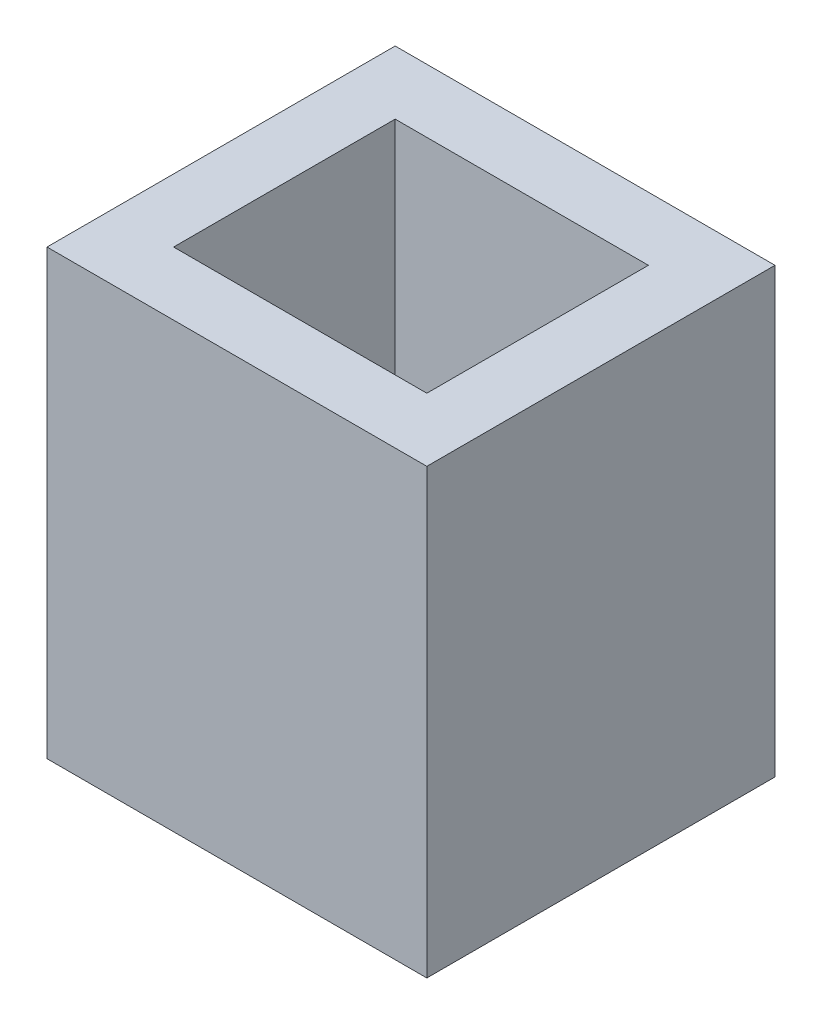
from build123d import *

# Parameters (mm, degrees)
SKETCH1_W           = 12
SKETCH1_H           = 11
BOSS_EXTRUDE1_DEPTH = 14
SHELL1_T            = -2
SKETCH2_R           = 0.75
CUT_EXTRUDE1_DEPTH  = 10


with BuildPart() as part:
    # Sketch1 → Boss-Extrude1 (new body)
    with BuildSketch(Plane(origin=(0, 0, 0), x_dir=(1, 0, 0), z_dir=(0, 1, 0))):
        with Locations((6, 5.5)):
            Rectangle(SKETCH1_W, SKETCH1_H)
    extrude(amount=BOSS_EXTRUDE1_DEPTH)

    # Shell1
    shell1_openings = [part.faces().sort_by_distance(p)[0] for p in [
        (6, 14, -5.5),
    ]]
    offset(amount=SHELL1_T, openings=shell1_openings, kind=Kind.INTERSECTION)

    # Sketch2 → Cut-Extrude1 (cut)
    with BuildSketch(Plane.XZ):
        with Locations((3.452899673, -7.28987771)):
            Circle(SKETCH2_R)
        with Locations((5.992899673, -7.28987771)):
            Circle(SKETCH2_R)
        with Locations((8.532899673, -7.28987771)):
            Circle(SKETCH2_R)
    extrude(amount=-CUT_EXTRUDE1_DEPTH, mode=Mode.SUBTRACT)


solid = part.part
